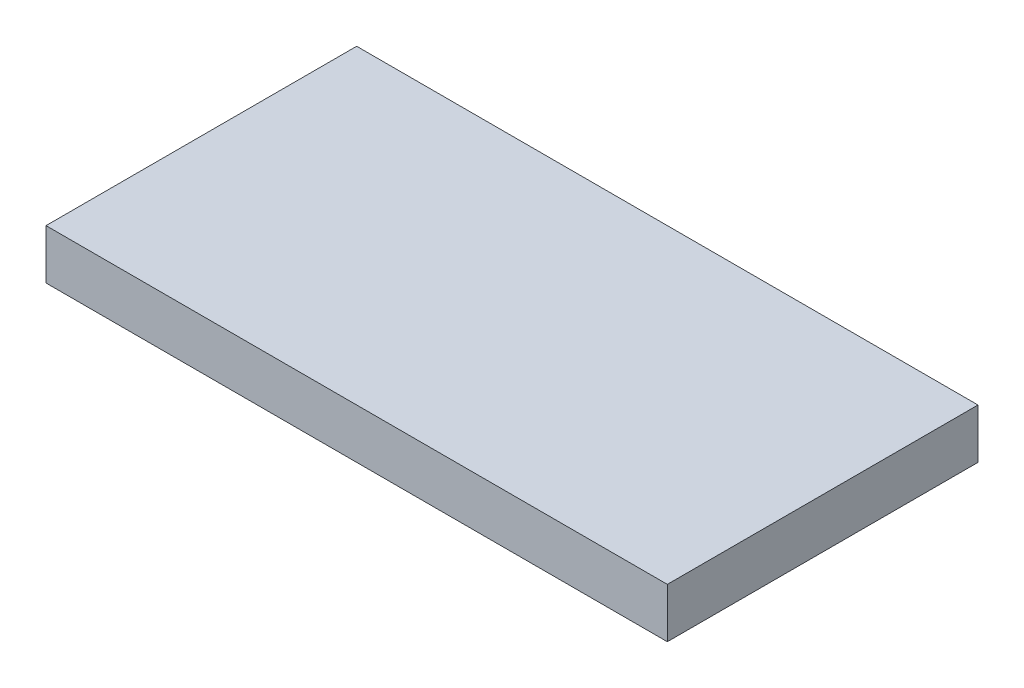
from build123d import *

# Parameters (mm, degrees)
SKETCH1_W           = 25.4
SKETCH1_H           = 12.7
BOSS_EXTRUDE1_DEPTH = 2.032


with BuildPart() as part:
    # Sketch1 → Boss-Extrude1 (new body)
    with BuildSketch(Plane(origin=(0, 0, 0), x_dir=(1, 0, 0), z_dir=(0, 1, 0))):
        with Locations((-12.7, 6.35)):
            Rectangle(SKETCH1_W, SKETCH1_H)
    extrude(amount=BOSS_EXTRUDE1_DEPTH)


solid = part.part
